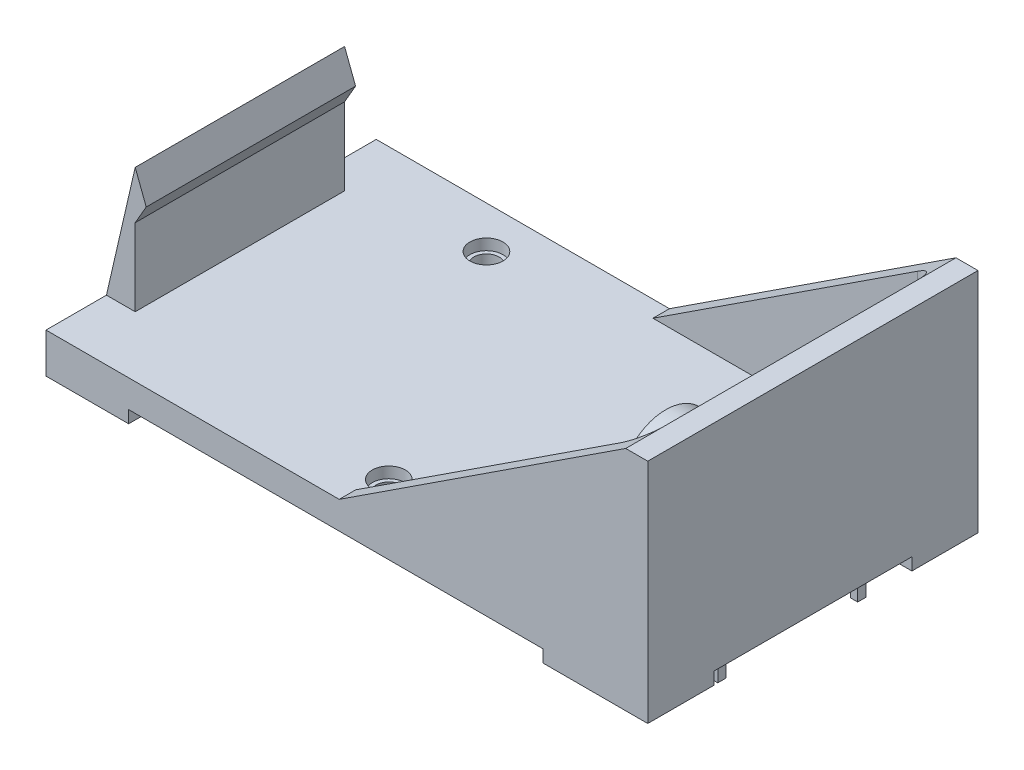
from build123d import *

# Parameters (mm, degrees)
SKETCH_1_W           = 54.61
SKETCH_1_H           = 29.97
EXTRUDE_1_DEPTH      = 2.5
EXTRUDE_2_DEPTH      = 17
CUT_EXTRUDE_1_DEPTH  = 30.97
SKETCH_4_R           = 1.145
CUT_EXTRUDE_2_DEPTH  = 3.5
SKETCH_5_R           = 2.25
SKETCH_5_W           = 7.5
SKETCH_5_H           = 6
SKETCH_5_W_2         = 9.5
EXTRUDE_3_DEPTH      = 1.12
SKETCH_6_R           = 1.145
CUT_EXTRUDE_3_DEPTH  = 4.62
SKETCH_7_R           = 1.5
CUT_EXTRUDE_4_DEPTH  = 1
EXTRUDE_4_DEPTH      = 9.5
EXTRUDE_4_DEPTH_BACK = 9.5
SKETCH_9_W           = 0.66
SKETCH_9_H           = 0.76
EXTRUDE_5_DEPTH      = 3
SKETCH_10_R          = 3.75
EXTRUDE_6_DEPTH      = 1
SKETCH_11_R          = 3
SKETCH_11_R_2        = 2
EXTRUDE_7_DEPTH      = 4
SKETCH_12_R          = 4.25
SKETCH_12_R_2        = 3.25
EXTRUDE_8_DEPTH      = 4


with BuildPart() as part:
    # Эскиз1 → Бобышка-Вытянуть1 (new body)
    with BuildSketch(Plane(origin=(0, 0, 0), x_dir=(1, 0, 0), z_dir=(0, 1, 0))):
        Rectangle(SKETCH_1_W, SKETCH_1_H)
    extrude(amount=EXTRUDE_1_DEPTH)

    # Эскиз2 → Бобышка-Вытянуть2 (add)
    with BuildSketch(Plane(origin=(0, 2.5, 0), x_dir=(1, 0, 0), z_dir=(0, 1, 0))):
        with BuildLine():
            Line((27.305, -14.985), (-0.695, -14.985))
            Line((-0.695, -14.985), (-0.695, -13.485))
            Line((-0.695, -13.485), (23.305, -13.485))
            ThreePointArc((23.305, -13.485), (24.719213562, -12.899213562), (25.305, -11.485))
            Line((25.305, -11.485), (25.305, 11.485))
            ThreePointArc((25.305, 11.485), (24.719213562, 12.899213562), (23.305, 13.485))
            Line((23.305, 13.485), (-0.695, 13.485))
            Line((-0.695, 13.485), (-0.695, 14.985))
            Line((-0.695, 14.985), (27.305, 14.985))
            Line((27.305, 14.985), (27.305, -14.985))
        make_face()
    extrude(amount=EXTRUDE_2_DEPTH)

    # Эскиз3 → Вырез-Вытянуть1 (cut, through all)
    with BuildSketch(Plane.XY.offset(14.985)):
        Polygon((-0.695, 2.5), (25.305, 19.5), (-0.695, 19.5), align=None)
    extrude(amount=-CUT_EXTRUDE_1_DEPTH, mode=Mode.SUBTRACT)

    # Эскиз4 → Вырез-Вытянуть2 (cut, through all)
    with BuildSketch(Plane(origin=(0, 2.5, 0), x_dir=(1, 0, 0), z_dir=(0, 1, 0))):
        with Locations((-13.495, 11.175)):
            Circle(SKETCH_4_R)
        with Locations((-0.005, -11.175)):
            Circle(SKETCH_4_R)
        with Locations((13.475, 11.175)):
            Circle(SKETCH_4_R)
    extrude(amount=-CUT_EXTRUDE_2_DEPTH, mode=Mode.SUBTRACT)

    # Эскиз5 → Бобышка-Вытянуть3 (add)
    with BuildSketch(Plane.XZ):
        with Locations((-0.005, 11.175)):
            Circle(SKETCH_5_R)
        with Locations((13.475, -11.175)):
            Circle(SKETCH_5_R)
        with Locations((-13.495, -11.175)):
            Circle(SKETCH_5_R)
        with Locations((-23.555, 11.985)):
            Rectangle(SKETCH_5_W, SKETCH_5_H)
        with Locations((22.555, 11.985)):
            Rectangle(SKETCH_5_W_2, SKETCH_5_H)
        with Locations((22.555, -11.985)):
            Rectangle(SKETCH_5_W_2, SKETCH_5_H)
        with Locations((-23.555, -11.985)):
            Rectangle(SKETCH_5_W, SKETCH_5_H)
    extrude(amount=EXTRUDE_3_DEPTH)

    # Эскиз6 → Вырез-Вытянуть3 (cut, through all)
    with BuildSketch(Plane(origin=(0, 2.5, 0), x_dir=(1, 0, 0), z_dir=(0, 1, 0))):
        with Locations((-13.495, 11.175)):
            Circle(SKETCH_6_R)
        with Locations((13.475, 11.175)):
            Circle(SKETCH_6_R)
        with Locations((-0.005, -11.175)):
            Circle(SKETCH_6_R)
    extrude(amount=-CUT_EXTRUDE_3_DEPTH, mode=Mode.SUBTRACT)

    # Эскиз7 → Вырез-Вытянуть4 (cut)
    with BuildSketch(Plane(origin=(0, 2.5, 0), x_dir=(1, 0, 0), z_dir=(0, 1, 0))):
        with Locations((-13.495, 11.175)):
            Circle(SKETCH_7_R)
        with Locations((13.475, 11.175)):
            Circle(SKETCH_7_R)
        with Locations((-0.005, -11.175)):
            Circle(SKETCH_7_R)
    extrude(amount=-CUT_EXTRUDE_4_DEPTH, mode=Mode.SUBTRACT)

    # Эскиз8 → Бобышка-Вытянуть4 (add, two sides)
    with BuildSketch(Plane.XY) as extrude_4_sk:
        Polygon((-27.305, 2.5), (-24.695, 13.85), (-23.695, 11.232050808), (-24.695, 9.5), (-24.695, 2.5), align=None)
    extrude(amount=EXTRUDE_4_DEPTH)
    extrude(extrude_4_sk.sketch, amount=-EXTRUDE_4_DEPTH_BACK)

    # Эскиз9 → Бобышка-Вытянуть5 (add)
    with BuildSketch(Plane.XZ):
        with Locations((25.075, 6.35)):
            Rectangle(SKETCH_9_W, SKETCH_9_H)
        with Locations((25.075, -6.35)):
            Rectangle(SKETCH_9_W, SKETCH_9_H)
    extrude(amount=EXTRUDE_5_DEPTH)

    # Эскиз10 → Бобышка-Вытянуть6 (add)
    with BuildSketch(Plane.ZY.offset(-25.305)):
        with Locations((-6.35, 11.48)):
            Circle(SKETCH_10_R)
        with Locations((6.35, 11.48)):
            Circle(SKETCH_10_R)
    extrude(amount=EXTRUDE_6_DEPTH)

    # Эскиз11 → Бобышка-Вытянуть7 (add)
    with BuildSketch(Plane.ZY.offset(-24.305)):
        with Locations((-6.35, 11.48)):
            Circle(SKETCH_11_R)
        with Locations((-6.35, 11.48)):
            Circle(SKETCH_11_R_2, mode=Mode.SUBTRACT)
    extrude(amount=EXTRUDE_7_DEPTH)

    # Эскиз12 → Бобышка-Вытянуть8 (add)
    with BuildSketch(Plane.ZY.offset(-24.305)):
        with Locations((6.35, 11.48)):
            Circle(SKETCH_12_R)
        with Locations((6.35, 11.48)):
            Circle(SKETCH_12_R_2, mode=Mode.SUBTRACT)
    extrude(amount=EXTRUDE_8_DEPTH)


solid = part.part
